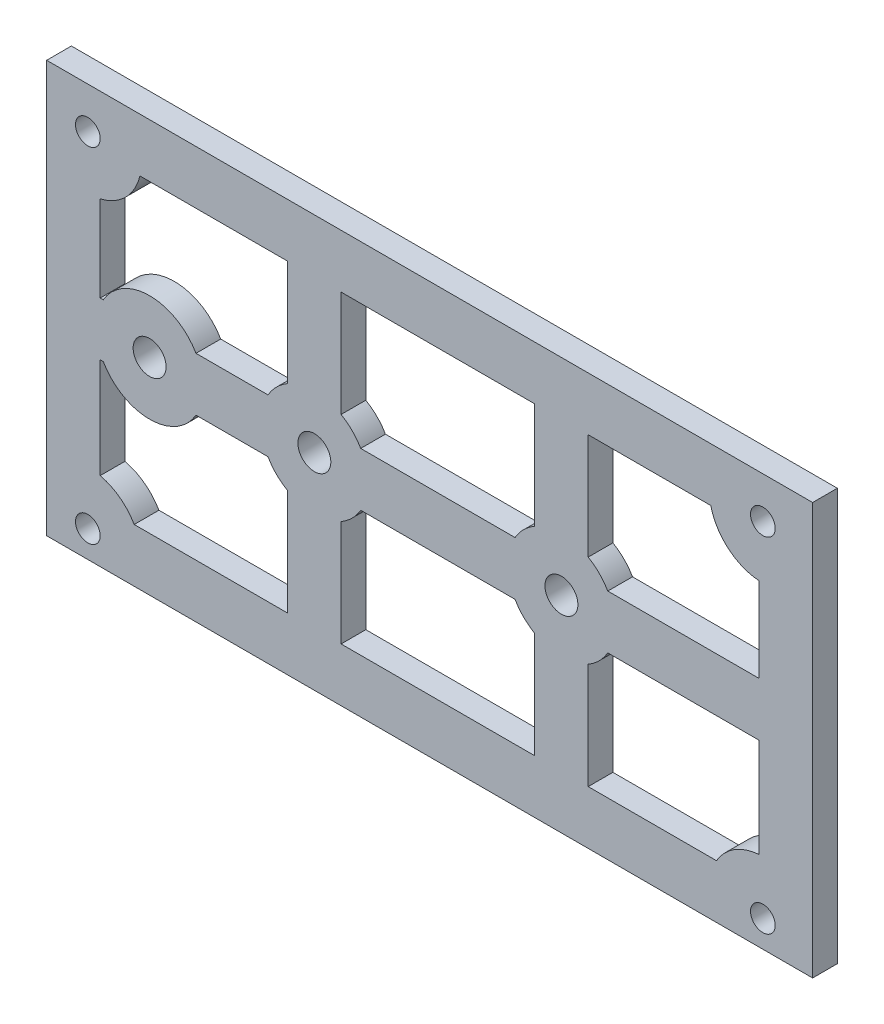
from build123d import *

# Parameters (mm, degrees)
SKETCH2_W           = 93
SKETCH2_H           = 50
BOSS_EXTRUDE1_DEPTH = 3
SKETCH1_R           = 1.5
SKETCH1_R_2         = 2
CUT_EXTRUDE9_DEPTH  = 4


with BuildPart() as part:
    # Sketch2 → Boss-Extrude1 (new body)
    with BuildSketch(Plane.XY):
        Rectangle(SKETCH2_W, SKETCH2_H)
    extrude(amount=BOSS_EXTRUDE1_DEPTH)

    # Sketch1 → Cut-Extrude9 (cut, through all)
    with BuildSketch(Plane.XY):
        with BuildLine():
            ThreePointArc((21.629165125, 3.25), (20.596194078, 4.596194078), (19.25, 5.629165125))
            Line((19.25, 5.629165125), (19.25, 18.5))
            Line((19.25, 18.5), (34.132524712, 18.5))
            ThreePointArc((34.132524712, 18.5), (36.249054116, 15.045959438), (40, 13.516090852))
            Line((40, 13.516090852), (40, 3.25))
            Line((40, 3.25), (21.629165125, 3.25))
        make_face()
        with BuildLine():
            ThreePointArc((12.75, 5.629165125), (11.403805922, 4.596194078), (10.370834875, 3.25))
            Line((10.370834875, 3.25), (-8.370834875, 3.25))
            ThreePointArc((-8.370834875, 3.25), (-9.403805922, 4.596194078), (-10.75, 5.629165125))
            Line((-10.75, 5.629165125), (-10.75, 18.5))
            Line((-10.75, 18.5), (12.75, 18.5))
            Line((12.75, 18.5), (12.75, 5.629165125))
        make_face()
        with BuildLine():
            ThreePointArc((-40, 13.67544468), (-36.903805922, 15.403805922), (-35.17544468, 18.5))
            Line((-35.17544468, 18.5), (-17.25, 18.5))
            Line((-17.25, 18.5), (-17.25, 5.629165125))
            ThreePointArc((-17.25, 5.629165125), (-18.596194078, 4.596194078), (-19.629165125, 3.25))
            Line((-19.629165125, 3.25), (-28.370834875, 3.25))
            ThreePointArc((-28.370834875, 3.25), (-34, 6.5), (-39.629165125, 3.25))
            Line((-39.629165125, 3.25), (-40, 3.25))
            Line((-40, 3.25), (-40, 13.67544468))
        make_face()
        with BuildLine():
            ThreePointArc((-35.871480673, -18.5), (-37.618576198, -16.537237855), (-40, -15.426562977))
            Line((-40, -15.426562977), (-40, -3.25))
            Line((-40, -3.25), (-39.629165125, -3.25))
            ThreePointArc((-39.629165125, -3.25), (-34, -6.5), (-28.370834875, -3.25))
            Line((-28.370834875, -3.25), (-19.629165125, -3.25))
            ThreePointArc((-19.629165125, -3.25), (-18.596194078, -4.596194078), (-17.25, -5.629165125))
            Line((-17.25, -5.629165125), (-17.25, -18.5))
            Line((-17.25, -18.5), (-35.871480673, -18.5))
        make_face()
        with BuildLine():
            ThreePointArc((-10.75, -5.629165125), (-9.403805922, -4.596194078), (-8.370834875, -3.25))
            Line((-8.370834875, -3.25), (10.370834875, -3.25))
            ThreePointArc((10.370834875, -3.25), (11.403805922, -4.596194078), (12.75, -5.629165125))
            Line((12.75, -5.629165125), (12.75, -18.5))
            Line((12.75, -18.5), (-10.75, -18.5))
            Line((-10.75, -18.5), (-10.75, -5.629165125))
        make_face()
        with BuildLine():
            ThreePointArc((19.25, -5.629165125), (20.596194078, -4.596194078), (21.629165125, -3.25))
            Line((21.629165125, -3.25), (40, -3.25))
            Line((40, -3.25), (40, -15.267209149))
            ThreePointArc((40, -15.267209149), (37.011595442, -16.239436527), (34.828560705, -18.5))
            Line((34.828560705, -18.5), (19.25, -18.5))
            Line((19.25, -18.5), (19.25, -5.629165125))
        make_face()
        with Locations((40.457080032, 20)):
            Circle(SKETCH1_R)
        with Locations((-41.5, 20)):
            Circle(SKETCH1_R)
        with Locations((-34, 0)):
            Circle(SKETCH1_R_2)
        with Locations((-14, 0)):
            Circle(SKETCH1_R_2)
        with Locations((16, 0)):
            Circle(SKETCH1_R_2)
        with Locations((40.457080032, -21.751118297)):
            Circle(SKETCH1_R)
        with Locations((-41.5, -21.751118297)):
            Circle(SKETCH1_R)
    extrude(amount=CUT_EXTRUDE9_DEPTH, mode=Mode.SUBTRACT)


solid = part.part
